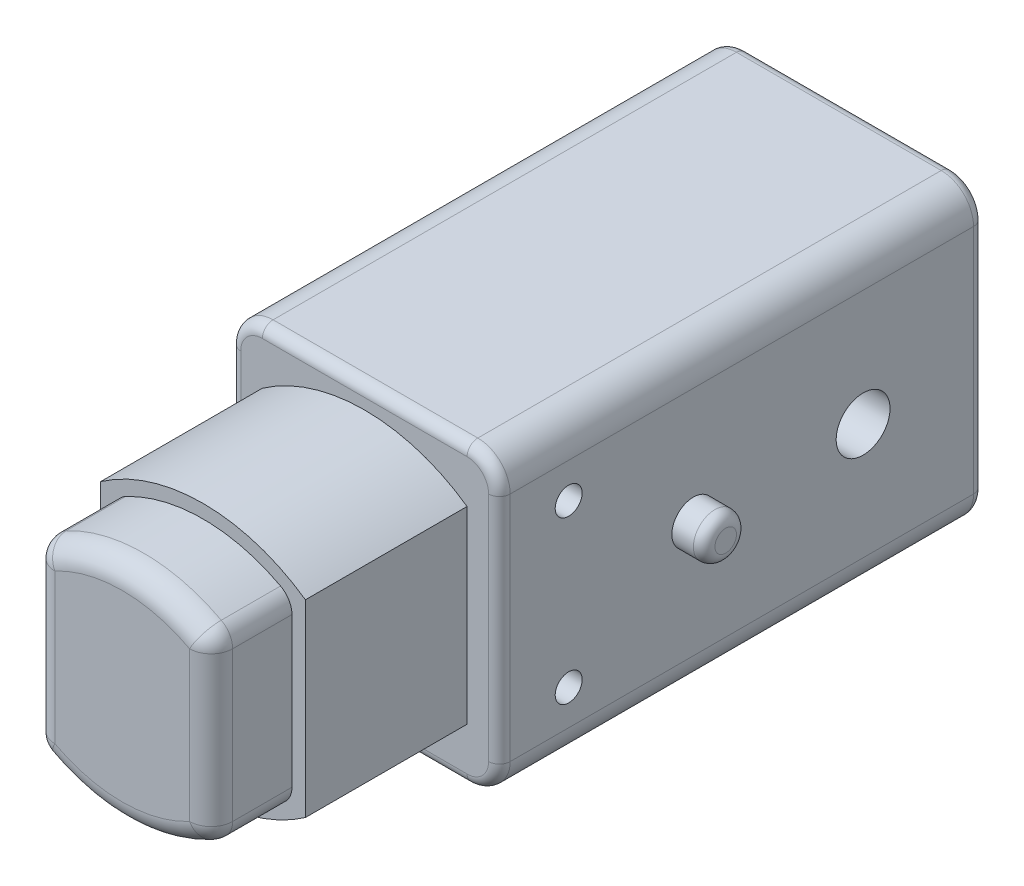
from build123d import *

# Parameters (mm, degrees)
MOTORBODY1_DEPTH            = 45
MOTORBODY2_DEPTH            = 15
SIDE_ENGRAVEMENT_SKETCH_R   = 1.25
SIDE_ENGRAVEMENT_SKETCH_R_2 = 2.5
CUT_EXTRUDE1_DEPTH          = 26
SIDE_ENGRAVEMENT_SKETCH_3_R = 2
BOSS_EXTRUDE3_DEPTH         = 3
SKETCH4_R                   = 3.5
BOSS_EXTRUDE5_DEPTH         = 5
FILLET1_R                   = 1
BOSS_EXTRUDE6_DEPTH         = 7.5
FILLET3_R                   = 2


with BuildPart() as part:
    # MotorMainSketch → MotorBody1 (new body)
    with BuildSketch(Plane.XY):
        with BuildLine():
            Line((-9.5, 13.75), (9.5, 13.75))
            ThreePointArc((9.5, 13.75), (11.621320344, 12.871320344), (12.5, 10.75))
            Line((12.5, 10.75), (12.5, -10.75))
            ThreePointArc((12.5, -10.75), (11.621320344, -12.871320344), (9.5, -13.75))
            Line((9.5, -13.75), (-9.5, -13.75))
            ThreePointArc((-9.5, -13.75), (-11.621320344, -12.871320344), (-12.5, -10.75))
            Line((-12.5, -10.75), (-12.5, 10.75))
            ThreePointArc((-12.5, 10.75), (-11.621320344, 12.871320344), (-9.5, 13.75))
        make_face()
    extrude(amount=MOTORBODY1_DEPTH)

    # side engravement sketch → Cut-Extrude1 (cut, through all)
    with BuildSketch(Plane(origin=(12.5, 0, 0), x_dir=(0, 0, -1), z_dir=(1, 0, 0))):
        with Locations((-38.571428571, 7.5)):
            Circle(SIDE_ENGRAVEMENT_SKETCH_R)
        with Locations((-38.571428571, -7.5)):
            Circle(SIDE_ENGRAVEMENT_SKETCH_R)
        with Locations((-11.25, 0)):
            Circle(SIDE_ENGRAVEMENT_SKETCH_R_2)
    extrude(amount=-CUT_EXTRUDE1_DEPTH, mode=Mode.SUBTRACT)

    # side engravement sketch_3 → Boss-Extrude3 (add)
    with BuildSketch(Plane(origin=(12.5, 0, 0), x_dir=(0, 0, -1), z_dir=(1, 0, 0))):
        with Locations((-27, 0)):
            Circle(SIDE_ENGRAVEMENT_SKETCH_3_R)
    extrude(amount=BOSS_EXTRUDE3_DEPTH)

    # Sketch4 → Boss-Extrude5 (add)
    with BuildSketch(Plane(origin=(0, 0, 0), x_dir=(-1, 0, 0), z_dir=(0, 0, -1))):
        Circle(SKETCH4_R)
    extrude(amount=BOSS_EXTRUDE5_DEPTH)

    # Fillet1
    fillet1_edges = [part.edges().sort_by_distance(p)[0] for p in [
        (-11.621320344, 12.871320344, 45),
        (0, 13.75, 0),
        (11.621320344, 12.871320344, 0),
        (-12.5, 0, 45),
        (-11.621320344, -12.871320344, 45),
        (0, -13.75, 45),
        (11.621320344, -12.871320344, 45),
        (12.5, 0, 45),
        (15.5, 0, 29),
        (11.621320344, 12.871320344, 45),
        (3.5, 0, -5),
        (0, 13.75, 45),
        (12.5, 0, 0),
        (11.621320344, -12.871320344, 0),
        (0, -13.75, 0),
        (-11.621320344, -12.871320344, 0),
        (-12.5, 0, 0),
        (-11.621320344, 12.871320344, 0),
    ]]
    fillet(fillet1_edges, radius=FILLET1_R)


with BuildPart() as body_2:
    # Motorsketch → MotorBody2 (new body)
    with BuildSketch(Plane.XY.offset(45)):
        with BuildLine():
            Line((-9.5, 8.75), (-9.5, -8.75))
            ThreePointArc((-9.5, -8.75), (0, -11.75), (9.5, -8.75))
            Line((9.5, -8.75), (9.5, 8.75))
            ThreePointArc((9.5, 8.75), (0, 11.75), (-9.5, 8.75))
        make_face()
    extrude(amount=MOTORBODY2_DEPTH)

    # Sketch5 → Boss-Extrude6 (add)
    with BuildSketch(Plane.XY.offset(60)):
        with BuildLine():
            Line((8.25, -8.083603018), (8.25, 8.083603018))
            ThreePointArc((8.25, 8.083603018), (0, 10.5), (-8.25, 8.083603018))
            Line((-8.25, 8.083603018), (-8.25, -8.083603018))
            ThreePointArc((-8.25, -8.083603018), (0, -10.5), (8.25, -8.083603018))
        make_face()
    extrude(amount=BOSS_EXTRUDE6_DEPTH)

    # Fillet3
    fillet3_edges = [body_2.edges().sort_by_distance(p)[0] for p in [
        (8.25, -8.083603018, 63.75),
        (8.25, 8.083603018, 63.75),
        (-8.25, 8.083603018, 63.75),
        (-8.25, -8.083603018, 63.75),
        (8.25, 0, 67.5),
        (0, 10.5, 67.5),
        (-8.25, 0, 67.5),
        (0, -10.5, 67.5),
    ]]
    fillet(fillet3_edges, radius=FILLET3_R)


solid = Compound([part.part, body_2.part])
